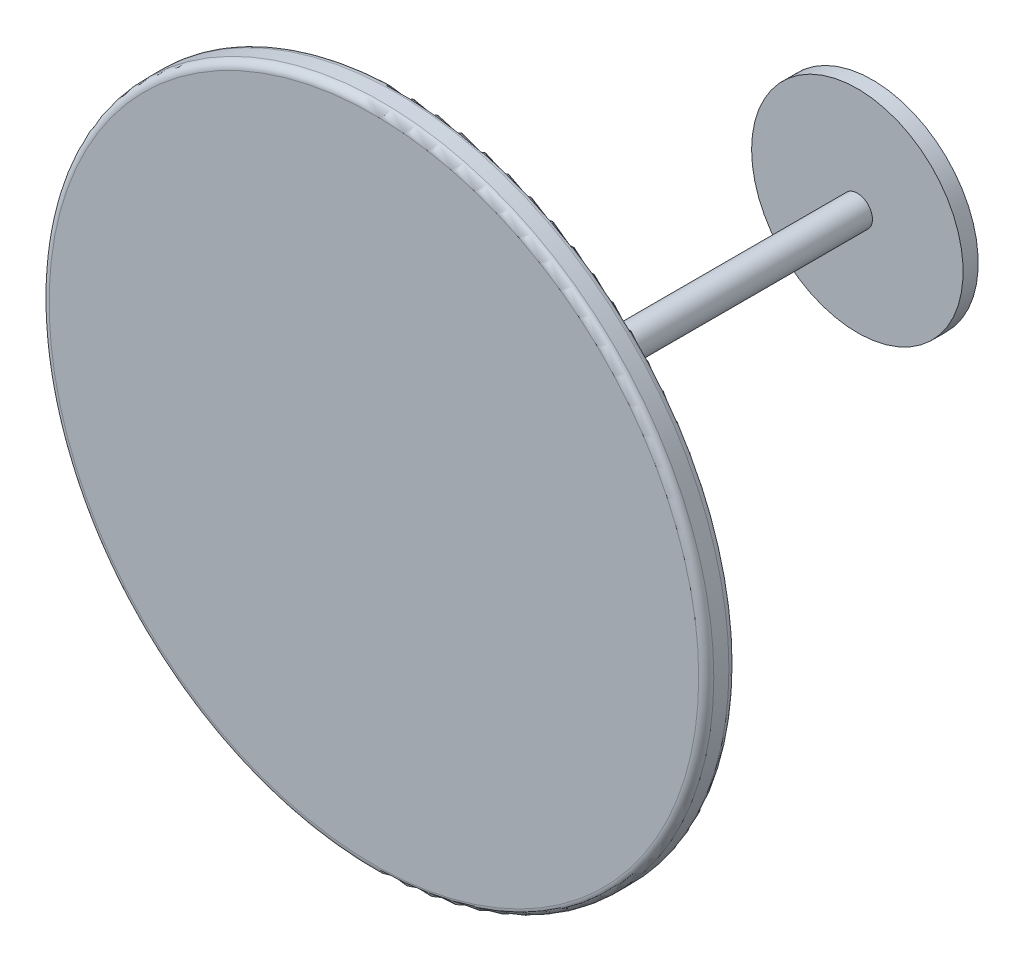
from build123d import *

# Parameters (mm, degrees)
SKETCH1_R               = 279.4
BASE_EXTRUDE_DEPTH      = 25.4
SKETCH5_R               = 12.7
BOSS_EXTRUDE1_DEPTH     = 381
FILLET2_R               = 6.35
CROQUIS1_R              = 88.9
SALIENTE_EXTRUIR1_DEPTH = 12.7


with BuildPart() as part:
    # Sketch1 → Base-Extrude (new body)
    with BuildSketch(Plane.XY):
        Circle(SKETCH1_R)
    extrude(amount=BASE_EXTRUDE_DEPTH)

    # Sketch5 → Boss-Extrude1 (add)
    with BuildSketch(Plane(origin=(0, 0, 0), x_dir=(-1, 0, 0), z_dir=(0, 0, -1))):
        Circle(SKETCH5_R)
    extrude(amount=BOSS_EXTRUDE1_DEPTH)

    # Fillet2
    fillet2_edges = [part.edges().sort_by_distance(p)[0] for p in [
        (-279.4, 0, 0),
        (-279.4, 0, 25.4),
    ]]
    fillet(fillet2_edges, radius=FILLET2_R)

    # Croquis1 → Saliente-Extruir1 (add)
    with BuildSketch(Plane(origin=(0, 0, -381), x_dir=(-1, 0, 0), z_dir=(0, 0, -1))):
        Circle(CROQUIS1_R)
    extrude(amount=SALIENTE_EXTRUIR1_DEPTH)


solid = part.part
